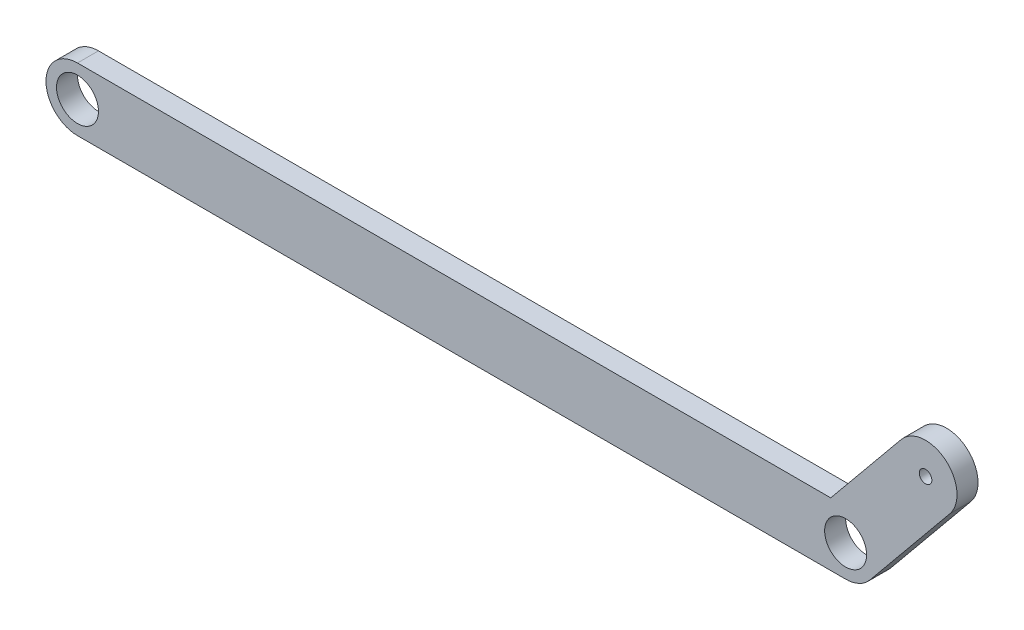
from build123d import *

# Parameters (mm, degrees)
SKETCH1_W           = 198
SKETCH1_H           = 15
BOSS_EXTRUDE1_DEPTH = 5
SKETCH2_R           = 5
CUT_EXTRUDE1_DEPTH  = 6
SKETCH3_R           = 1.5
BOSS_EXTRUDE2_DEPTH = 5


with BuildPart() as part:
    # Sketch1 → Boss-Extrude1 (new body)
    with BuildSketch(Plane.XY):
        with Locations((52.20591631, 1.643835616)):
            Rectangle(SKETCH1_W, SKETCH1_H)
    extrude(amount=BOSS_EXTRUDE1_DEPTH)

    # Sketch2 → Cut-Extrude1 (cut, through all)
    with BuildSketch(Plane.XY.offset(5)):
        with BuildLine():
            Line((-39.29408369, 9.143835616), (-46.79408369, 9.143835616))
            Line((-46.79408369, 9.143835616), (-46.79408369, 1.643835616))
            ThreePointArc((-46.79408369, 1.643835616), (-44.597384548, 6.947136475), (-39.29408369, 9.143835616))
        make_face()
        with BuildLine():
            ThreePointArc((-39.29408369, -5.856164384), (-44.597384548, -3.659465242), (-46.79408369, 1.643835616))
            Line((-46.79408369, 1.643835616), (-46.79408369, -5.856164384))
            Line((-46.79408369, -5.856164384), (-39.29408369, -5.856164384))
        make_face()
        with BuildLine():
            Line((151.20591631, 9.143835616), (143.70591631, 9.143835616))
            ThreePointArc((143.70591631, 9.143835616), (149.009217169, 6.947136475), (151.20591631, 1.643835616))
            Line((151.20591631, 1.643835616), (151.20591631, 9.143835616))
        make_face()
        with BuildLine():
            ThreePointArc((151.20591631, 1.643835616), (149.009217169, -3.659465242), (143.70591631, -5.856164384))
            Line((143.70591631, -5.856164384), (151.20591631, -5.856164384))
            Line((151.20591631, -5.856164384), (151.20591631, 1.643835616))
        make_face()
        with Locations((-39.29408369, 1.643835616)):
            Circle(SKETCH2_R)
        with Locations((143.70591631, 1.643835616)):
            Circle(SKETCH2_R)
    extrude(amount=-CUT_EXTRUDE1_DEPTH, mode=Mode.SUBTRACT)

    # Sketch3 → Boss-Extrude2 (add)
    with BuildSketch(Plane.XY.offset(5)):
        with BuildLine():
            ThreePointArc((143.70591631, 9.143835616), (150.486406082, 4.849293221), (149.50180231, -3.116175463))
            Line((149.50180231, -3.116175463), (168.541846628, 20.067368536))
            ThreePointArc((168.541846628, 20.067368536), (167.505971708, 30.623265615), (156.950074629, 29.587390695))
            Line((156.950074629, 29.587390695), (140.160312255, 9.143835616))
            Line((140.160312255, 9.143835616), (143.70591631, 9.143835616))
        make_face()
        with Locations((162.745960629, 24.827379616)):
            Circle(SKETCH3_R, mode=Mode.SUBTRACT)
    extrude(amount=-BOSS_EXTRUDE2_DEPTH)


solid = part.part
